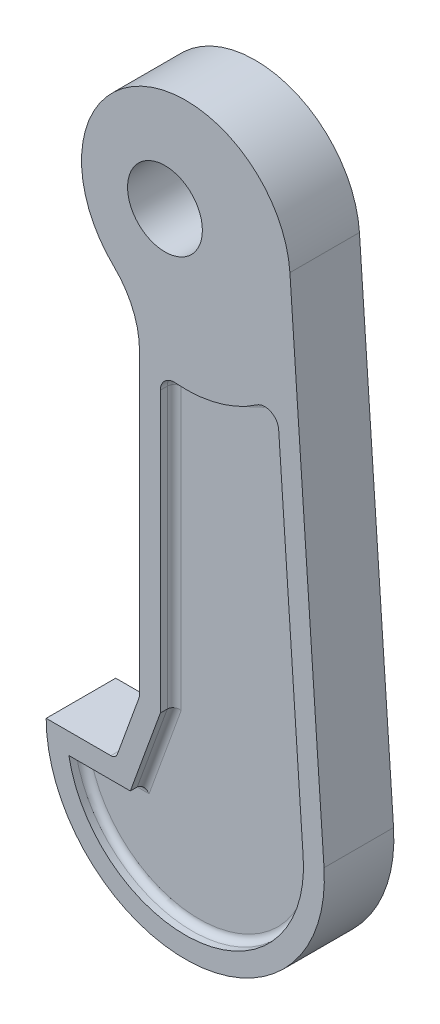
from build123d import *

# Parameters (mm, degrees)
SKETCH2_R           = 5.379907511
BOSS_EXTRUDE1_DEPTH = 5
CUT_EXTRUDE1_DEPTH  = 2
FILLET1_R           = 1
FILLET2_R           = 12


with BuildPart() as part:
    # Sketch2 → Boss-Extrude1 (new body, symmetric)
    with BuildSketch(Plane.XY):
        with BuildLine():
            Line((1.956537451, -8.000102101), (1.956537451, -57.164379656))
            Line((1.956537451, -57.164379656), (-1.463663982, -66.561305864))
            Line((-1.463663982, -66.561305864), (-11.463663982, -66.561305864))
            ThreePointArc((-11.463663982, -66.561305864), (9.219617422, -86.549630619), (28.48964867, -65.195540804))
            Line((28.48964867, -65.195540804), (23.58476107, 6.463017931))
            ThreePointArc((23.58476107, 6.463017931), (0.281599066, 17.907647409), (1.956537451, -8.000102101))
        make_face()
        with Locations((5.619776581, 5.438694136)):
            Circle(SKETCH2_R, mode=Mode.SUBTRACT)
    extrude(amount=BOSS_EXTRUDE1_DEPTH, both=True)

    # Sketch5 → Cut-Extrude1 (cut)
    with BuildSketch(Plane.XY.offset(5)):
        with BuildLine():
            Line((4.956537451, -17.492026764), (4.956537451, -57.693360598))
            Line((4.956537451, -57.693360598), (0.636958632, -69.561305864))
            Line((0.636958632, -69.561305864), (-8.196864513, -69.561305864))
            ThreePointArc((-8.196864513, -69.561305864), (10.619883032, -83.433141325), (25.496651772, -65.400405563))
            Line((25.496651772, -65.400405563), (21.970749815, -13.888307203))
            ThreePointArc((21.970749815, -13.888307203), (20.844130084, -12.223400912), (18.839854353, -12.378525925))
            ThreePointArc((18.839854353, -12.378525925), (13.252017954, -14.955050138), (7.122861364, -15.498954674))
            ThreePointArc((7.122861364, -15.498954674), (5.602404486, -16.020183052), (4.956537451, -17.492026764))
        make_face()
    cut_extrude1 = extrude(amount=-CUT_EXTRUDE1_DEPTH, mode=Mode.SUBTRACT)

    # Mirror1: Cut-Extrude1 across plane
    add(cut_extrude1.mirror(Plane.XY), mode=Mode.SUBTRACT)

    # Fillet1
    fillet1_edges = [part.edges().sort_by_distance(p)[0] for p in [
        (1.956537451, -57.164379656, 0),
        (-1.463663982, -66.561305864, 0),
        (13.252017954, -14.955050138, 3),
        (20.844130084, -12.223400912, 3),
        (23.733700794, -39.644356383, 3),
        (10.619883032, -83.433141325, 3),
        (-3.77995294, -69.561305864, 3),
        (2.796748042, -63.627333231, 3),
        (4.956537451, -37.592693681, 3),
        (5.602404486, -16.020183052, 3),
        (13.252017954, -14.955050138, -3),
        (5.602404486, -16.020183052, -3),
        (4.956537451, -37.592693681, -3),
        (2.796748042, -63.627333231, -3),
        (-3.77995294, -69.561305864, -3),
        (10.619883032, -83.433141325, -3),
        (23.733700794, -39.644356383, -3),
        (20.844130084, -12.223400912, -3),
    ]]
    fillet(fillet1_edges, radius=FILLET1_R)

    # Fillet2
    fillet2_edges = [part.edges().sort_by_distance(p)[0] for p in [
        (1.956537451, -8.000102101, 0),
    ]]
    fillet(fillet2_edges, radius=FILLET2_R)


solid = part.part
